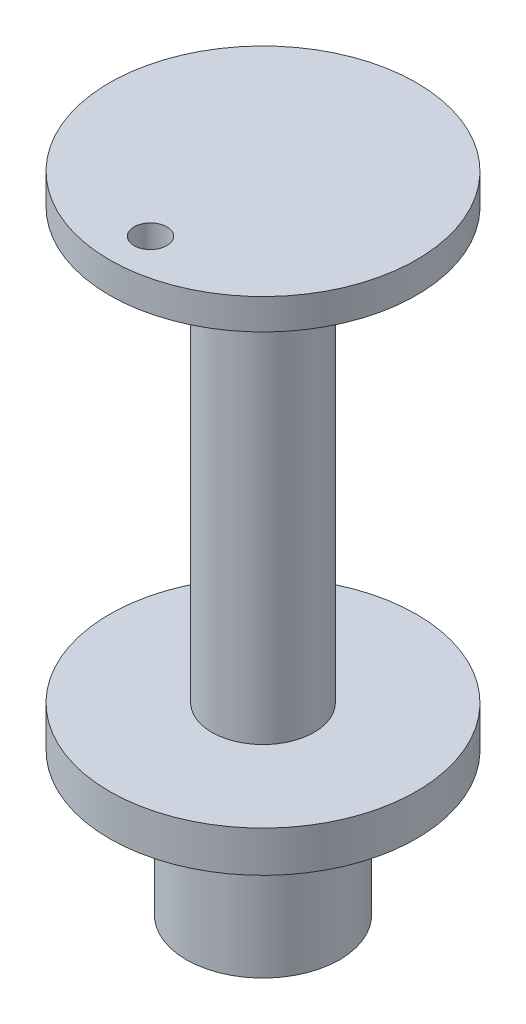
from build123d import *

# Parameters (mm, degrees)
SKETCH1_R           = 15
BOSS_EXTRUDE1_DEPTH = 2
SKETCH2_R           = 7.5
SKETCH2_R_2         = 6.3
BOSS_EXTRUDE2_DEPTH = 14
SKETCH4_R           = 5
BOSS_EXTRUDE3_DEPTH = 42
SKETCH5_R           = 15
BOSS_EXTRUDE4_DEPTH = 3
SKETCH6_R           = 1.6
CUT_EXTRUDE1_DEPTH  = 3


with BuildPart() as part:
    # Sketch1 → Boss-Extrude1 (new body, symmetric)
    with BuildSketch(Plane(origin=(0, 0, 0), x_dir=(1, 0, 0), z_dir=(0, 1, 0))):
        Circle(SKETCH1_R)
    extrude(amount=BOSS_EXTRUDE1_DEPTH, both=True)

    # Sketch2 → Boss-Extrude2 (add)
    with BuildSketch(Plane.XZ.offset(2)):
        Circle(SKETCH2_R)
        Circle(SKETCH2_R_2, mode=Mode.SUBTRACT)
    extrude(amount=BOSS_EXTRUDE2_DEPTH)

    # Sketch4 → Boss-Extrude3 (add)
    with BuildSketch(Plane(origin=(0, 2, 0), x_dir=(1, 0, 0), z_dir=(0, 1, 0))):
        Circle(SKETCH4_R)
    extrude(amount=BOSS_EXTRUDE3_DEPTH)

    # Sketch5 → Boss-Extrude4 (add)
    with BuildSketch(Plane(origin=(0, 44, 0), x_dir=(1, 0, 0), z_dir=(0, 1, 0))):
        Circle(SKETCH5_R)
    extrude(amount=BOSS_EXTRUDE4_DEPTH)

    # Sketch6 → Cut-Extrude1 (cut)
    with BuildSketch(Plane(origin=(0, 47, 0), x_dir=(1, 0, 0), z_dir=(0, 1, 0))):
        with Locations((0, -11)):
            Circle(SKETCH6_R)
    extrude(amount=-CUT_EXTRUDE1_DEPTH, mode=Mode.SUBTRACT)


solid = part.part
